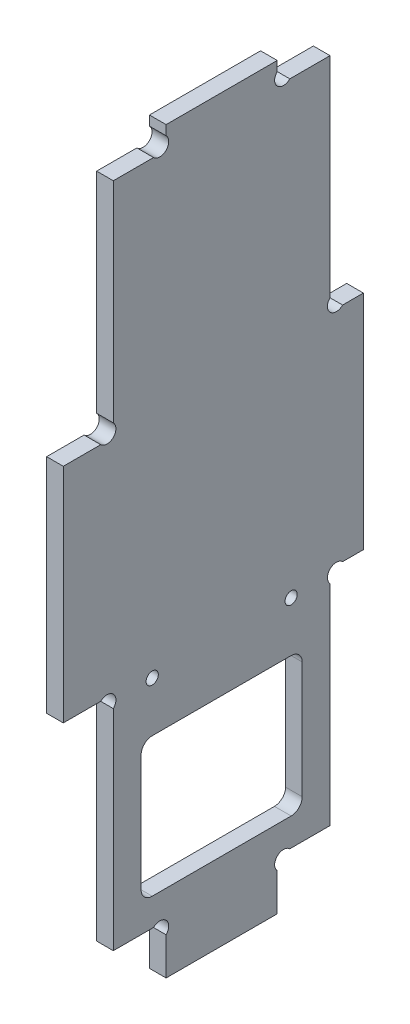
from build123d import *

# Parameters (mm, degrees)
EXTRUSION1_DEPTH        = 3
ESQUISSE2_W             = 29
ESQUISSE2_H             = 25
ENL_V_MAT_EXTRU_1_DEPTH = 4
CONG_1_R                = 2
ESQUISSE3_R             = 1.1
ENL_V_MAT_EXTRU_2_DEPTH = 4


with BuildPart() as part:
    # Esquisse1 → Extrusion1 (new body)
    with BuildSketch(Plane(origin=(0, 0, 0), x_dir=(0, 0, -1), z_dir=(1, 0, 0))):
        with BuildLine():
            Line((18.5, 6.7372583), (18.5, 0))
            Line((18.5, 0), (38.5, 0))
            Line((38.5, 0), (38.5, 6.7372583))
            ThreePointArc((38.5, 6.7372583), (38.5, 9), (40.7627417, 9))
            Line((40.7627417, 9), (48, 9))
            Line((48, 9), (48, 46.7372583))
            ThreePointArc((48, 46.7372583), (48, 49), (50.2627417, 49))
            Line((50.2627417, 49), (54, 49))
            Line((54, 49), (54, 89))
            Line((54, 89), (50.2627417, 89))
            ThreePointArc((50.2627417, 89), (48, 89), (48, 91.2627417))
            Line((48, 91.2627417), (48, 129))
            Line((48, 129), (40.7627417, 129))
            ThreePointArc((40.7627417, 129), (38.5, 129), (38.5, 131.2627417))
            Line((38.5, 131.2627417), (38.5, 133))
            Line((38.5, 133), (18.5, 133))
            Line((18.5, 133), (18.5, 131.2627417))
            ThreePointArc((18.5, 131.2627417), (18.5, 129), (16.2372583, 129))
            Line((16.2372583, 129), (9, 129))
            Line((9, 129), (9, 91.2627417))
            ThreePointArc((9, 91.2627417), (9, 89), (6.7372583, 89))
            Line((6.7372583, 89), (0, 89))
            Line((0, 89), (0, 49))
            Line((0, 49), (6.7372583, 49))
            ThreePointArc((6.7372583, 49), (9, 49), (9, 46.7372583))
            Line((9, 46.7372583), (9, 9))
            Line((9, 9), (16.2372583, 9))
            ThreePointArc((16.2372583, 9), (18.5, 9), (18.5, 6.7372583))
        make_face()
    extrude(amount=EXTRUSION1_DEPTH)

    # Esquisse2 → Enlèv. mat.-Extru.1 (cut, through all)
    with BuildSketch(Plane(origin=(3, 0, 0), x_dir=(0, 0, -1), z_dir=(1, 0, 0))):
        with Locations((28.5, 26.5)):
            Rectangle(ESQUISSE2_W, ESQUISSE2_H)
    extrude(amount=-ENL_V_MAT_EXTRU_1_DEPTH, mode=Mode.SUBTRACT)

    # Congé1
    cong_1_edges = [part.edges().sort_by_distance(p)[0] for p in [
        (1.5, 14, -14),
        (1.5, 39, -14),
        (1.5, 39, -43),
        (1.5, 14, -43),
    ]]
    fillet(cong_1_edges, radius=CONG_1_R)

    # Esquisse3 → Enlèv. mat.-Extru.2 (cut, through all)
    with BuildSketch(Plane(origin=(3, 0, 0), x_dir=(0, 0, -1), z_dir=(1, 0, 0))):
        with Locations((16, 48)):
            Circle(ESQUISSE3_R)
        with Locations((41, 48)):
            Circle(ESQUISSE3_R)
    extrude(amount=-ENL_V_MAT_EXTRU_2_DEPTH, mode=Mode.SUBTRACT)


solid = part.part
